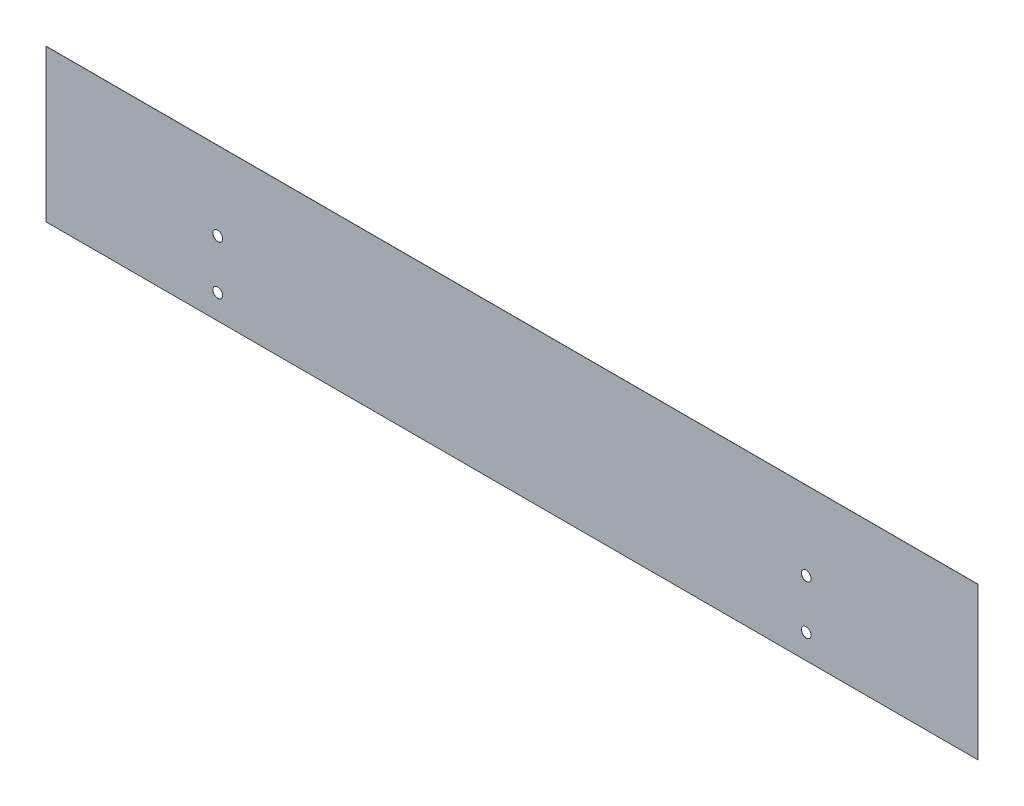
from build123d import *

# Parameters (mm, degrees)
SKETCH1_W             = 380
SKETCH1_H             = 62
BODY_DEPTH            = 0.0625
SKETCH2_R             = 2
MAGNETIC_HOLDER_DEPTH = 0.0625


with BuildPart() as part:
    # Sketch1 → Body (new body)
    with BuildSketch(Plane.XY):
        Rectangle(SKETCH1_W, SKETCH1_H)
    extrude(amount=BODY_DEPTH)

    # Sketch2 → Magnetic Holder (cut)
    with BuildSketch(Plane.XY.offset(0.0625)):
        with Locations((-120, -1)):
            Circle(SKETCH2_R)
        with Locations((120, -1)):
            Circle(SKETCH2_R)
        with Locations((120, -21)):
            Circle(SKETCH2_R)
        with Locations((-120, -21)):
            Circle(SKETCH2_R)
    extrude(amount=-MAGNETIC_HOLDER_DEPTH, mode=Mode.SUBTRACT)


solid = part.part
